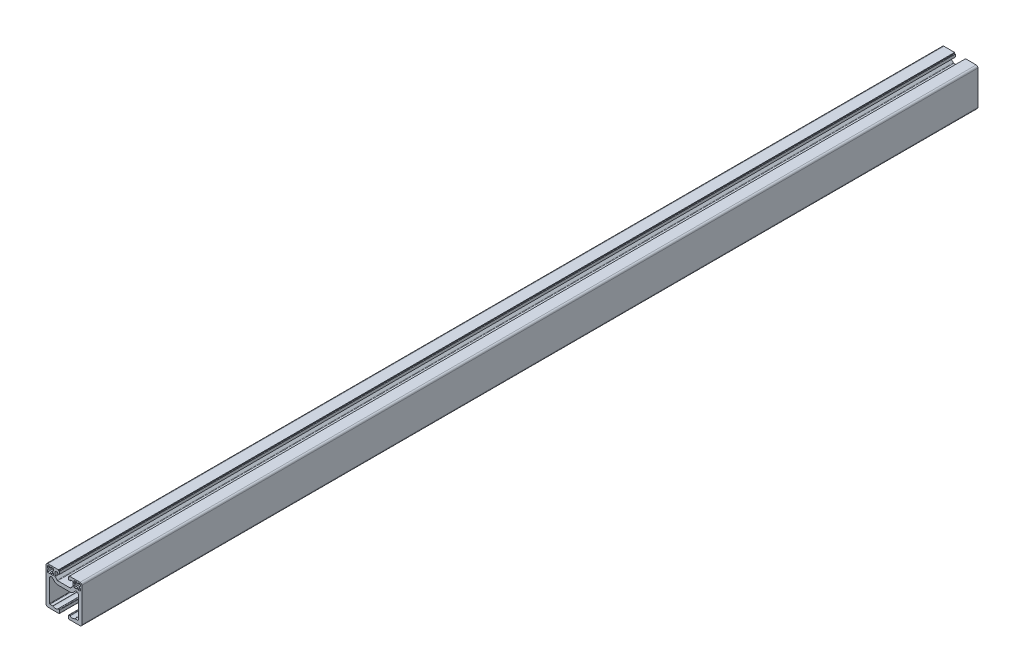
from build123d import *

# Parameters (mm, degrees)
EXTRUDE_1_DEPTH = 1000


with BuildPart() as part:
    # Эскиз1 → Бобышка-Вытянуть1 (new body)
    with BuildSketch(Plane.XY):
        with BuildLine():
            Line((-15.5, -17), (-12.5, -17))
            ThreePointArc((-12.5, -17), (-12.341886117, -17.025658351), (-12.2, -17.1))
            ThreePointArc((-12.2, -17.1), (-9.5, -18), (-6.8, -17.1))
            ThreePointArc((-6.8, -17.1), (-6.658113883, -17.025658351), (-6.5, -17))
            Line((-6.5, -17), (-5.5, -17))
            ThreePointArc((-5.5, -17), (-5.146446609, -17.146446609), (-5, -17.5))
            Line((-5, -17.5), (-5, -20.5))
            ThreePointArc((-5, -20.5), (-5.146446609, -20.853553391), (-5.5, -21))
            Line((-5.5, -21), (-18, -21))
            ThreePointArc((-18, -21), (-19.414213562, -20.414213562), (-20, -19))
            Line((-20, -19), (-20, 19))
            ThreePointArc((-20, 19), (-19.414213562, 20.414213562), (-18, 21))
            Line((-18, 21), (-6.1, 21))
            Line((-6.1, 21), (-6.1, 20))
            Line((-6.1, 20), (-5.1, 20))
            Line((-5.1, 20), (-5.1, 17))
            Line((-5.1, 17), (-7.1, 17))
            Line((-7.1, 17), (-7.1, 18))
            Line((-7.1, 18), (-9, 18))
            ThreePointArc((-9, 18), (-9.707106781, 17.707106781), (-10, 17))
            Line((-10, 17), (-10, 13.181980515))
            ThreePointArc((-10, 13.181980515), (-9.923879533, 12.799297083), (-9.707106781, 12.474873734))
            Line((-9.707106781, 12.474873734), (-7.525126266, 10.292893219))
            ThreePointArc((-7.525126266, 10.292893219), (-7.200702917, 10.076120467), (-6.818019485, 10))
            Line((-6.818019485, 10), (6.818019485, 10))
            ThreePointArc((6.818019485, 10), (7.200702917, 10.076120467), (7.525126266, 10.292893219))
            Line((7.525126266, 10.292893219), (9.707106781, 12.474873734))
            ThreePointArc((9.707106781, 12.474873734), (9.923879533, 12.799297083), (10, 13.181980515))
            Line((10, 13.181980515), (10, 17))
            ThreePointArc((10, 17), (9.707106781, 17.707106781), (9, 18))
            Line((9, 18), (7.1, 18))
            Line((7.1, 18), (7.1, 17))
            Line((7.1, 17), (5.1, 17))
            Line((5.1, 17), (5.1, 20))
            Line((5.1, 20), (6.1, 20))
            Line((6.1, 20), (6.1, 21))
            Line((6.1, 21), (18, 21))
            ThreePointArc((18, 21), (19.414213562, 20.414213562), (20, 19))
            Line((20, 19), (20, -19))
            ThreePointArc((20, -19), (19.414213562, -20.414213562), (18, -21))
            Line((18, -21), (5.5, -21))
            ThreePointArc((5.5, -21), (5.146446609, -20.853553391), (5, -20.5))
            Line((5, -20.5), (5, -17.5))
            ThreePointArc((5, -17.5), (5.146446609, -17.146446609), (5.5, -17))
            Line((5.5, -17), (6.5, -17))
            ThreePointArc((6.5, -17), (6.658113883, -17.025658351), (6.8, -17.1))
            ThreePointArc((6.8, -17.1), (9.5, -18), (12.2, -17.1))
            ThreePointArc((12.2, -17.1), (12.341886117, -17.025658351), (12.5, -17))
            Line((12.5, -17), (15.5, -17))
            ThreePointArc((15.5, -17), (15.853553391, -16.853553391), (16, -16.5))
            Line((16, -16.5), (16, 8.282485579))
            ThreePointArc((16, 8.282485579), (14.765366865, 10.130244644), (12.585786438, 9.696699141))
            Line((12.585786438, 9.696699141), (10.353553391, 7.464466094))
            ThreePointArc((10.353553391, 7.464466094), (8.731436646, 6.380602337), (6.818019485, 6))
            Line((6.818019485, 6), (-6.818019485, 6))
            ThreePointArc((-6.818019485, 6), (-8.731436646, 6.380602337), (-10.353553391, 7.464466094))
            Line((-10.353553391, 7.464466094), (-12.585786438, 9.696699141))
            ThreePointArc((-12.585786438, 9.696699141), (-14.765366865, 10.130244644), (-16, 8.282485579))
            Line((-16, 8.282485579), (-16, -16.5))
            ThreePointArc((-16, -16.5), (-15.853553391, -16.853553391), (-15.5, -17))
        make_face()
        with BuildLine():
            Line((-11.5, 12.5), (-14.2, 12.5))
            Line((-14.2, 12.5), (-14.2, 13.5))
            Line((-14.2, 13.5), (-15.8, 13.5))
            Line((-15.8, 13.5), (-15.8, 12.5))
            Line((-15.8, 12.5), (-18.5, 12.5))
            Line((-18.5, 12.5), (-18.5, 15.2))
            Line((-18.5, 15.2), (-17.5, 15.2))
            Line((-17.5, 15.2), (-17.5, 16.8))
            Line((-17.5, 16.8), (-18.5, 16.8))
            Line((-18.5, 16.8), (-18.5, 18.5))
            ThreePointArc((-18.5, 18.5), (-18.207106781, 19.207106781), (-17.5, 19.5))
            Line((-17.5, 19.5), (-15.8, 19.5))
            Line((-15.8, 19.5), (-15.8, 18.5))
            Line((-15.8, 18.5), (-14.2, 18.5))
            Line((-14.2, 18.5), (-14.2, 19.5))
            Line((-14.2, 19.5), (-11.5, 19.5))
            Line((-11.5, 19.5), (-11.5, 16.8))
            Line((-11.5, 16.8), (-12.5, 16.8))
            Line((-12.5, 16.8), (-12.5, 15.2))
            Line((-12.5, 15.2), (-11.5, 15.2))
            Line((-11.5, 15.2), (-11.5, 12.5))
        make_face(mode=Mode.SUBTRACT)
        with BuildLine():
            Line((17.5, 16.8), (18.5, 16.8))
            Line((18.5, 16.8), (18.5, 18.5))
            ThreePointArc((18.5, 18.5), (18.207106781, 19.207106781), (17.5, 19.5))
            Line((17.5, 19.5), (15.8, 19.5))
            Line((15.8, 19.5), (15.8, 18.5))
            Line((15.8, 18.5), (14.2, 18.5))
            Line((14.2, 18.5), (14.2, 19.5))
            Line((14.2, 19.5), (11.5, 19.5))
            Line((11.5, 19.5), (11.5, 16.8))
            Line((11.5, 16.8), (12.5, 16.8))
            Line((12.5, 16.8), (12.5, 15.2))
            Line((12.5, 15.2), (11.5, 15.2))
            Line((11.5, 15.2), (11.5, 12.5))
            Line((11.5, 12.5), (14.2, 12.5))
            Line((14.2, 12.5), (14.2, 13.5))
            Line((14.2, 13.5), (15.8, 13.5))
            Line((15.8, 13.5), (15.8, 12.5))
            Line((15.8, 12.5), (18.5, 12.5))
            Line((18.5, 12.5), (18.5, 15.2))
            Line((18.5, 15.2), (17.5, 15.2))
            Line((17.5, 15.2), (17.5, 16.8))
        make_face(mode=Mode.SUBTRACT)
    extrude(amount=EXTRUDE_1_DEPTH)


solid = part.part
